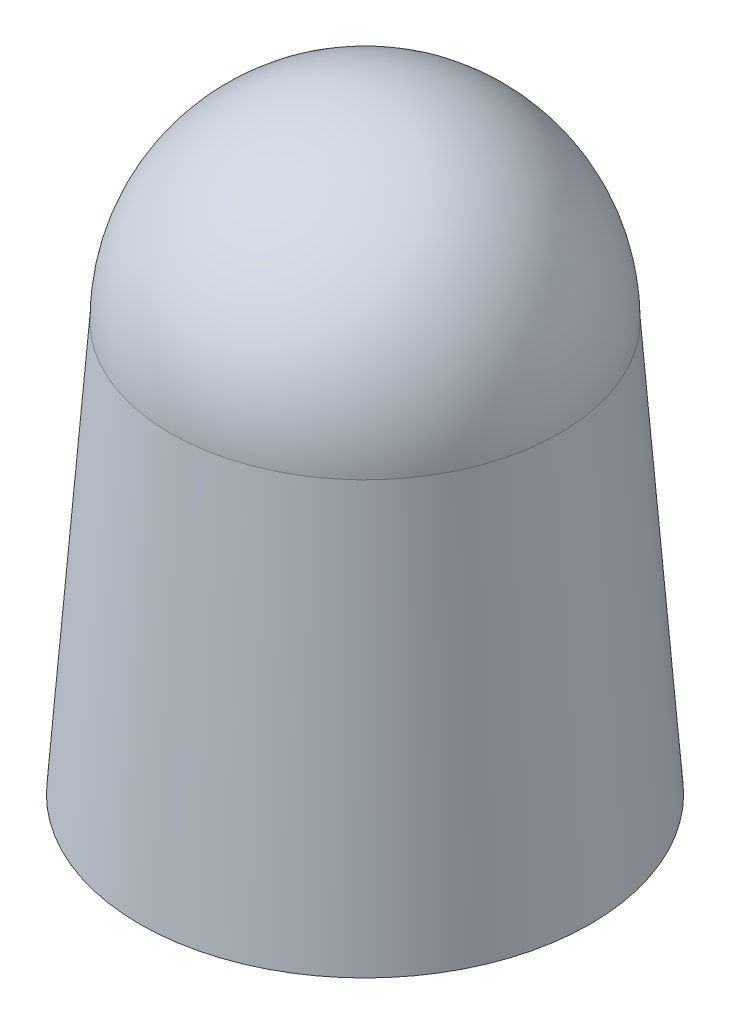
from build123d import *

# Parameters (mm, degrees)
SKETCH6_R          = 8.5
CUT_EXTRUDE1_DEPTH = 20
SKETCH8_R          = 10.802442882
SKETCH8_R_2        = 8.707562746
CUT_EXTRUDE2_DEPTH = 0.5
REVOLVE2_ANGLE     = 180


with BuildPart() as part:
    # Sketch3 → Revolve1 (revolve)
    with BuildSketch(Plane.XY):
        Polygon((0, 0), (11, 0), (9.5, 20), (0, 20), align=None)
    revolve(axis=Axis((0, 0, 0), (0, 1, 0)))

    # Sketch6 → Cut-Extrude1 (cut)
    with BuildSketch(Plane(origin=(0, 20, 0), x_dir=(1, 0, 0), z_dir=(0, 1, 0))):
        Circle(SKETCH6_R)
    extrude(amount=-CUT_EXTRUDE1_DEPTH, mode=Mode.SUBTRACT)

    # Sketch7 → Cut-Revolve1 (revolve, cut)
    with BuildSketch(Plane.XY):
        Polygon((8.5, 19.6), (8.5, 0.4), (10.568876578, 0.4), (9.128876578, 19.6), align=None)
    revolve(axis=Axis((0, 0, 0), (0, 1, 0)), mode=Mode.SUBTRACT)

    # Sketch8 → Cut-Extrude2 (cut)
    with BuildSketch(Plane(origin=(0, 0, 0), x_dir=(-1, 0, 0), z_dir=(0, -1, 0))):
        Circle(SKETCH8_R)
        Circle(SKETCH8_R_2, mode=Mode.SUBTRACT)
    extrude(amount=-CUT_EXTRUDE2_DEPTH, mode=Mode.SUBTRACT)

    # Sketch10 → Revolve2 (revolve)
    with BuildSketch(Plane(origin=(0, 20, 0), x_dir=(1, 0, 0), z_dir=(0, 1, 0))):
        with BuildLine():
            Line((0, 9.5), (0, -9.5))
            ThreePointArc((0, -9.5), (9.5, 0), (0, 9.5))
        make_face()
    revolve(axis=Axis((0, 20, -9.5), (0, 0, 1)), revolution_arc=REVOLVE2_ANGLE)


solid = part.part
